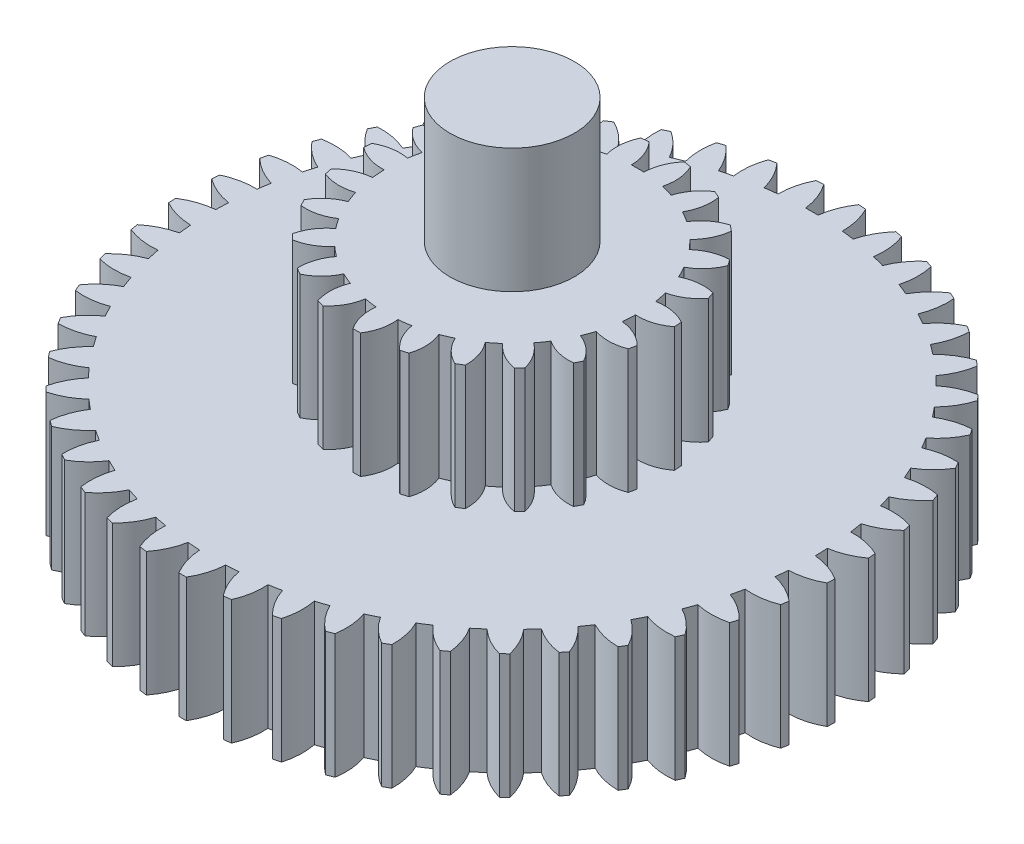
from build123d import *

# Parameters (mm, degrees)
BOSS_EXTRUDE1_DEPTH      = 1
SKETCH2_R                = 0.5
BOSS_EXTRUDE2_DEPTH      = 2
BOSS_EXTRUDE2_DEPTH_BACK = 2
BOSS_EXTRUDE3_DEPTH      = 1


with BuildPart() as part:
    # Sketch1 → Boss-Extrude1 (new body)
    with BuildSketch(Plane(origin=(0, 0, 0), x_dir=(1, 0, 0), z_dir=(0, 1, 0))):
        with BuildLine():
            ThreePointArc((-2.476479155, 0.943160111), (-2.486941318, 0.915217394), (-2.497088209, 0.887158654))
            ThreePointArc((-2.497088209, 0.887158654), (-2.405681699, 0.798131231), (-2.295665859, 0.733497284))
            ThreePointArc((-2.295665859, 0.733497284), (-2.310389526, 0.685711484), (-2.324118617, 0.637630499))
            ThreePointArc((-2.324118617, 0.637630499), (-2.451581658, 0.643479038), (-2.576755933, 0.618731655))
            ThreePointArc((-2.576755933, 0.618731655), (-2.583558967, 0.589680475), (-2.59003448, 0.560554541))
            ThreePointArc((-2.59003448, 0.560554541), (-2.487993842, 0.483946837), (-2.370616024, 0.433912047))
            ThreePointArc((-2.370616024, 0.433912047), (-2.379108098, 0.384635747), (-2.386576014, 0.335193869))
            ThreePointArc((-2.386576014, 0.335193869), (-2.513740479, 0.324694779), (-2.63472245, 0.284143641))
            ThreePointArc((-2.63472245, 0.284143641), (-2.637754649, 0.254461019), (-2.640452456, 0.224746138))
            ThreePointArc((-2.640452456, 0.224746138), (-2.529453195, 0.161816049), (-2.406640741, 0.127201987))
            ThreePointArc((-2.406640741, 0.127201987), (-2.408761781, 0.077244302), (-2.409845898, 0.027253365))
            ThreePointArc((-2.409845898, 0.027253365), (-2.534623752, 0.000579042), (-2.649426898, -0.055110003))
            ThreePointArc((-2.649426898, -0.055110003), (-2.648638473, -0.084936681), (-2.647514276, -0.114752591))
            ThreePointArc((-2.647514276, -0.114752591), (-2.529378996, -0.162971754), (-2.403148482, -0.181596727))
            ThreePointArc((-2.403148482, -0.181596727), (-2.398863662, -0.231415492), (-2.39354618, -0.281134638))
            ThreePointArc((-2.39354618, -0.281134638), (-2.513888572, -0.323546203), (-2.620627829, -0.393458742))
            ThreePointArc((-2.620627829, -0.393458742), (-2.616031726, -0.422939722), (-2.611103985, -0.452367085))
            ThreePointArc((-2.611103985, -0.452367085), (-2.487772464, -0.485083565), (-2.360196593, -0.487413627))
            ThreePointArc((-2.360196593, -0.487413627), (-2.349576268, -0.536275451), (-2.337944499, -0.584906419))
            ThreePointArc((-2.337944499, -0.584906419), (-2.451875411, -0.642358829), (-2.548798124, -0.7253469))
            ThreePointArc((-2.548798124, -0.7253469), (-2.540469811, -0.753998105), (-2.531819439, -0.782553724))
            ThreePointArc((-2.531819439, -0.782553724), (-2.405316777, -0.799230317), (-2.27849034, -0.78522721))
            ThreePointArc((-2.27849034, -0.78522721), (-2.261708897, -0.832329781), (-2.243953835, -0.879074052))
            ThreePointArc((-2.243953835, -0.879074052), (-2.349602524, -0.95062394), (-2.435117223, -1.045324882))
            ThreePointArc((-2.435117223, -1.045324882), (-2.423193451, -1.072675859), (-2.410962487, -1.099890852))
            ThreePointArc((-2.410962487, -1.099890852), (-2.283365855, -1.100253729), (-2.159371339, -1.070147383))
            ThreePointArc((-2.159371339, -1.070147383), (-2.136704328, -1.114717279), (-2.11311751, -1.158807313))
            ThreePointArc((-2.11311751, -1.158807313), (-2.208749229, -1.243279832), (-2.281451766, -1.348138658))
            ThreePointArc((-2.281451766, -1.348138658), (-2.266128322, -1.373740306), (-2.250517598, -1.399167803))
            ThreePointArc((-2.250517598, -1.399167803), (-2.123922129, -1.383211006), (-2.00479552, -1.337495765))
            ThreePointArc((-2.00479552, -1.337495765), (-1.976615134, -1.378801151), (-1.947583854, -1.419512991))
            ThreePointArc((-1.947583854, -1.419512991), (-2.031628332, -1.515521104), (-2.090324933, -1.628816034))
            ThreePointArc((-2.090324933, -1.628816034), (-2.071853429, -1.652247975), (-2.053119272, -1.675470458))
            ThreePointArc((-2.053119272, -1.675470458), (-1.92960366, -1.643455996), (-1.817301015, -1.582882504))
            ThreePointArc((-1.817301015, -1.582882504), (-1.784069973, -1.620245146), (-1.750070925, -1.656910304))
            ThreePointArc((-1.750070925, -1.656910304), (-1.821148154, -1.762877562), (-1.864875023, -1.882748297))
            ThreePointArc((-1.864875023, -1.882748297), (-1.843558759, -1.903625778), (-1.822008785, -1.924261933))
            ThreePointArc((-1.822008785, -1.924261933), (-1.703601153, -1.876715485), (-1.599966476, -1.802278357))
            ThreePointArc((-1.599966476, -1.802278357), (-1.562230433, -1.83508476), (-1.523821881, -1.867101196))
            ThreePointArc((-1.523821881, -1.867101196), (-1.580764774, -1.981287618), (-1.608803916, -2.105765884))
            ThreePointArc((-1.608803916, -2.105765884), (-1.584992906, -2.123746098), (-1.560980963, -2.141457081))
            ThreePointArc((-1.560980963, -2.141457081), (-1.449625561, -2.079159357), (-1.356360533, -1.992080848))
            ThreePointArc((-1.356360533, -1.992080848), (-1.314739112, -2.019792333), (-1.272551722, -2.046634338))
            ThreePointArc((-1.272551722, -2.046634338), (-1.31442528, -2.167164987), (-1.326316294, -2.294206854))
            ThreePointArc((-1.326316294, -2.294206854), (-1.300401513, -2.308994566), (-1.274321878, -2.323489563))
            ThreePointArc((-1.274321878, -2.323489563), (-1.171847158, -2.247463489), (-1.090483187, -2.149173427))
            ThreePointArc((-1.090483187, -2.149173427), (-1.045659811, -2.171334972), (-1.0003863, -2.192561801))
            ThreePointArc((-1.0003863, -2.192561801), (-1.026502959, -2.317457566), (-1.022050595, -2.44497701))
            ThreePointArc((-1.022050595, -2.44497701), (-0.994457563, -2.456329407), (-0.966738462, -2.467370411))
            ThreePointArc((-0.966738462, -2.467370411), (-0.874827057, -2.378864334), (-0.806700137, -2.270976638))
            ThreePointArc((-0.806700137, -2.270976638), (-0.759410805, -2.28722435), (-0.711794563, -2.302487459))
            ThreePointArc((-0.711794563, -2.302487459), (-0.721725488, -2.429697557), (-0.701002853, -2.555600712))
            ThreePointArc((-0.701002853, -2.555600712), (-0.672184647, -2.563331387), (-0.643281228, -2.570737105))
            ThreePointArc((-0.643281228, -2.570737105), (-0.56344232, -2.471204291), (-0.509671094, -2.355490475))
            ThreePointArc((-0.509671094, -2.355490475), (-0.460692295, -2.365557568), (-0.411515178, -2.374606338))
            ThreePointArc((-0.411515178, -2.374606338), (-0.405097304, -2.50204198), (-0.368444664, -2.624261521))
            ThreePointArc((-0.368444664, -2.624261521), (-0.338874478, -2.628243537), (-0.309261333, -2.631892366))
            ThreePointArc((-0.309261333, -2.631892366), (-0.242805876, -2.522967143), (-0.204273265, -2.401327223))
            ThreePointArc((-0.204273265, -2.401327223), (-0.15440923, -2.405048397), (-0.104478725, -2.407734245))
            ThreePointArc((-0.104478725, -2.407734245), (-0.081817434, -2.533302944), (-0.029836623, -2.649832028))
            ThreePointArc((-0.029836623, -2.649832028), (0, -2.65), (0.029836623, -2.649832028))
            ThreePointArc((0.029836623, -2.649832028), (0.081817434, -2.533302944), (0.104478725, -2.407734245))
            ThreePointArc((0.104478725, -2.407734245), (0.15440923, -2.405048397), (0.204273265, -2.401327223))
            ThreePointArc((0.204273265, -2.401327223), (0.242805876, -2.522967143), (0.309261333, -2.631892366))
            ThreePointArc((0.309261333, -2.631892366), (0.338874478, -2.628243537), (0.368444664, -2.624261521))
            ThreePointArc((0.368444664, -2.624261521), (0.405097304, -2.50204198), (0.411515178, -2.374606338))
            ThreePointArc((0.411515178, -2.374606338), (0.460692295, -2.365557568), (0.509671094, -2.355490475))
            ThreePointArc((0.509671094, -2.355490475), (0.56344232, -2.471204291), (0.643281228, -2.570737105))
            ThreePointArc((0.643281228, -2.570737105), (0.672184647, -2.563331387), (0.701002853, -2.555600712))
            ThreePointArc((0.701002853, -2.555600712), (0.721725488, -2.429697557), (0.711794563, -2.302487459))
            ThreePointArc((0.711794563, -2.302487459), (0.759410805, -2.28722435), (0.806700137, -2.270976638))
            ThreePointArc((0.806700137, -2.270976638), (0.874827057, -2.378864334), (0.966738462, -2.467370411))
            ThreePointArc((0.966738462, -2.467370411), (0.994457563, -2.456329407), (1.022050595, -2.44497701))
            ThreePointArc((1.022050595, -2.44497701), (1.026502959, -2.317457566), (1.0003863, -2.192561801))
            ThreePointArc((1.0003863, -2.192561801), (1.045659811, -2.171334972), (1.090483187, -2.149173427))
            ThreePointArc((1.090483187, -2.149173427), (1.171847158, -2.247463489), (1.274321878, -2.323489563))
            ThreePointArc((1.274321878, -2.323489563), (1.300401513, -2.308994566), (1.326316294, -2.294206854))
            ThreePointArc((1.326316294, -2.294206854), (1.31442528, -2.167164987), (1.272551722, -2.046634338))
            ThreePointArc((1.272551722, -2.046634338), (1.314739112, -2.019792333), (1.356360533, -1.992080848))
            ThreePointArc((1.356360533, -1.992080848), (1.449625561, -2.079159357), (1.560980963, -2.141457081))
            ThreePointArc((1.560980963, -2.141457081), (1.584992906, -2.123746098), (1.608803916, -2.105765884))
            ThreePointArc((1.608803916, -2.105765884), (1.580764774, -1.981287618), (1.523821881, -1.867101196))
            ThreePointArc((1.523821881, -1.867101196), (1.562230433, -1.83508476), (1.599966476, -1.802278357))
            ThreePointArc((1.599966476, -1.802278357), (1.703601153, -1.876715485), (1.822008785, -1.924261933))
            ThreePointArc((1.822008785, -1.924261933), (1.843558759, -1.903625778), (1.864875023, -1.882748297))
            ThreePointArc((1.864875023, -1.882748297), (1.821148154, -1.762877562), (1.750070925, -1.656910304))
            ThreePointArc((1.750070925, -1.656910304), (1.784069973, -1.620245146), (1.817301015, -1.582882504))
            ThreePointArc((1.817301015, -1.582882504), (1.92960366, -1.643455996), (2.053119272, -1.675470458))
            ThreePointArc((2.053119272, -1.675470458), (2.071853429, -1.652247975), (2.090324933, -1.628816034))
            ThreePointArc((2.090324933, -1.628816034), (2.031628332, -1.515521104), (1.947583854, -1.419512991))
            ThreePointArc((1.947583854, -1.419512991), (1.976615134, -1.378801151), (2.00479552, -1.337495765))
            ThreePointArc((2.00479552, -1.337495765), (2.123922129, -1.383211006), (2.250517598, -1.399167803))
            ThreePointArc((2.250517598, -1.399167803), (2.266128322, -1.373740306), (2.281451766, -1.348138658))
            ThreePointArc((2.281451766, -1.348138658), (2.208749229, -1.243279832), (2.11311751, -1.158807313))
            ThreePointArc((2.11311751, -1.158807313), (2.136704328, -1.114717279), (2.159371339, -1.070147383))
            ThreePointArc((2.159371339, -1.070147383), (2.283365855, -1.100253729), (2.410962487, -1.099890852))
            ThreePointArc((2.410962487, -1.099890852), (2.423193451, -1.072675859), (2.435117223, -1.045324882))
            ThreePointArc((2.435117223, -1.045324882), (2.349602524, -0.95062394), (2.243953835, -0.879074052))
            ThreePointArc((2.243953835, -0.879074052), (2.261708897, -0.832329781), (2.27849034, -0.78522721))
            ThreePointArc((2.27849034, -0.78522721), (2.405316777, -0.799230317), (2.531819439, -0.782553724))
            ThreePointArc((2.531819439, -0.782553724), (2.540469811, -0.753998105), (2.548798124, -0.7253469))
            ThreePointArc((2.548798124, -0.7253469), (2.451875411, -0.642358829), (2.337944499, -0.584906419))
            ThreePointArc((2.337944499, -0.584906419), (2.349576268, -0.536275451), (2.360196593, -0.487413627))
            ThreePointArc((2.360196593, -0.487413627), (2.487772464, -0.485083565), (2.611103985, -0.452367085))
            ThreePointArc((2.611103985, -0.452367085), (2.616031726, -0.422939722), (2.620627829, -0.393458742))
            ThreePointArc((2.620627829, -0.393458742), (2.513888572, -0.323546203), (2.39354618, -0.281134638))
            ThreePointArc((2.39354618, -0.281134638), (2.398863662, -0.231415492), (2.403148482, -0.181596727))
            ThreePointArc((2.403148482, -0.181596727), (2.529378996, -0.162971754), (2.647514276, -0.114752591))
            ThreePointArc((2.647514276, -0.114752591), (2.648638473, -0.084936681), (2.649426898, -0.055110003))
            ThreePointArc((2.649426898, -0.055110003), (2.534623752, 0.000579042), (2.409845898, 0.027253365))
            ThreePointArc((2.409845898, 0.027253365), (2.408761781, 0.077244302), (2.406640741, 0.127201987))
            ThreePointArc((2.406640741, 0.127201987), (2.529453195, 0.161816049), (2.640452456, 0.224746138))
            ThreePointArc((2.640452456, 0.224746138), (2.637754649, 0.254461019), (2.63472245, 0.284143641))
            ThreePointArc((2.63472245, 0.284143641), (2.513740479, 0.324694779), (2.386576014, 0.335193869))
            ThreePointArc((2.386576014, 0.335193869), (2.379108098, 0.384635747), (2.370616024, 0.433912047))
            ThreePointArc((2.370616024, 0.433912047), (2.487993842, 0.483946837), (2.59003448, 0.560554541))
            ThreePointArc((2.59003448, 0.560554541), (2.583558967, 0.589680475), (2.576755933, 0.618731655))
            ThreePointArc((2.576755933, 0.618731655), (2.451581658, 0.643479038), (2.324118617, 0.637630499))
            ThreePointArc((2.324118617, 0.637630499), (2.310389526, 0.685711484), (2.295665859, 0.733497284))
            ThreePointArc((2.295665859, 0.733497284), (2.405681699, 0.798131231), (2.497088209, 0.887158654))
            ThreePointArc((2.497088209, 0.887158654), (2.486941318, 0.915217394), (2.476479155, 0.943160111))
            ThreePointArc((2.476479155, 0.943160111), (2.349167934, 0.951697388), (2.223499257, 0.929597253))
            ThreePointArc((2.223499257, 0.929597253), (2.203734421, 0.975527857), (2.183020923, 1.021038516))
            ThreePointArc((2.183020923, 1.021038516), (2.283868329, 1.099210332), (2.363139819, 1.199195646))
            ThreePointArc((2.363139819, 1.199195646), (2.349488162, 1.225726469), (2.335538657, 1.252101905))
            ThreePointArc((2.335538657, 1.252101905), (2.208180937, 1.244288893), (2.086370101, 1.206300047))
            ThreePointArc((2.086370101, 1.206300047), (2.060894059, 1.24932609), (2.034530844, 1.291814323))
            ThreePointArc((2.034530844, 1.291814323), (2.124553904, 1.38224043), (2.190388738, 1.491541879))
            ThreePointArc((2.190388738, 1.491541879), (2.173456475, 1.516109149), (2.156248679, 1.54048422))
            ThreePointArc((2.156248679, 1.54048422), (2.03093567, 1.516449209), (1.914982805, 1.463195427))
            ThreePointArc((1.914982805, 1.463195427), (1.884213873, 1.502610422), (1.852633825, 1.541378575))
            ThreePointArc((1.852633825, 1.541378575), (1.930354363, 1.642574178), (1.981671535, 1.759397036))
            ThreePointArc((1.981671535, 1.759397036), (1.961736692, 1.781597359), (1.941553158, 1.803571827))
            ThreePointArc((1.941553158, 1.803571827), (1.820342495, 1.763709471), (1.712151544, 1.696065178))
            ThreePointArc((1.712151544, 1.696065178), (1.676594947, 1.731221934), (1.640316609, 1.765633433))
            ThreePointArc((1.640316609, 1.765633433), (1.704458457, 1.875936904), (1.74041534, 1.998362941))
            ThreePointArc((1.74041534, 1.998362941), (1.717805248, 2.01783179), (1.694977387, 2.037044835))
            ThreePointArc((1.694977387, 2.037044835), (1.579859347, 1.982009672), (1.481206803, 1.901085586))
            ThreePointArc((1.481206803, 1.901085586), (1.441446378, 1.931406829), (1.401065441, 1.96089664))
            ThreePointArc((1.401065441, 1.96089664), (1.45057539, 2.078496797), (1.470581573, 2.204515783))
            ThreePointArc((1.470581573, 2.204515783), (1.445667488, 2.220933478), (1.420570134, 2.237069622))
            ThreePointArc((1.420570134, 2.237069622), (1.313434953, 2.167765329), (1.225940687, 2.074890222))
            ThreePointArc((1.225940687, 2.074890222), (1.1826293, 2.099878077), (1.138808816, 2.123961977))
            ThreePointArc((1.138808816, 2.123961977), (1.172873915, 2.246927831), (1.176600897, 2.374470537))
            ThreePointArc((1.176600897, 2.374470537), (1.149791909, 2.3875675), (1.122837159, 2.400361788))
            ThreePointArc((1.122837159, 2.400361788), (1.025443992, 2.31792634), (0.950544658, 2.214625217))
            ThreePointArc((0.950544658, 2.214625217), (0.904393482, 2.233869385), (0.857852982, 2.252151918))
            ThreePointArc((0.857852982, 2.252151918), (0.875913883, 2.378464372), (0.863300467, 2.505436549))
            ThreePointArc((0.863300467, 2.505436549), (0.835036778, 2.51499773), (0.806667229, 2.52424008))
            ThreePointArc((0.806667229, 2.52424008), (0.72061527, 2.430027064), (0.659540713, 2.317996128))
            ThreePointArc((0.659540713, 2.317996128), (0.611307547, 2.33118062), (0.562811226, 2.343361586))
            ThreePointArc((0.562811226, 2.343361586), (0.564571369, 2.470946593), (0.535824668, 2.595263363))
            ThreePointArc((0.535824668, 2.595263363), (0.506570366, 2.601131766), (0.477251846, 2.606670419))
            ThreePointArc((0.477251846, 2.606670419), (0.403954065, 2.50222681), (0.357707127, 2.383305606))
            ThreePointArc((0.357707127, 2.383305606), (0.30818396, 2.390213933), (0.258528126, 2.396093322))
            ThreePointArc((0.258528126, 2.396093322), (0.243958609, 2.52285594), (0.199550642, 2.642476025))
            ThreePointArc((0.199550642, 2.642476025), (0.169786083, 2.644555291), (0.14, 2.646299303))
            ThreePointArc((0.14, 2.646299303), (0.080659945, 2.533340062), (0.05, 2.409481272))
            ThreePointArc((0.05, 2.409481272), (0, 2.41), (-0.05, 2.409481272))
            ThreePointArc((-0.05, 2.409481272), (-0.080659945, 2.533340062), (-0.14, 2.646299303))
            ThreePointArc((-0.14, 2.646299303), (-0.169786083, 2.644555291), (-0.199550642, 2.642476025))
            ThreePointArc((-0.199550642, 2.642476025), (-0.243958609, 2.52285594), (-0.258528126, 2.396093322))
            ThreePointArc((-0.258528126, 2.396093322), (-0.30818396, 2.390213933), (-0.357707127, 2.383305606))
            ThreePointArc((-0.357707127, 2.383305606), (-0.403954065, 2.50222681), (-0.477251846, 2.606670419))
            ThreePointArc((-0.477251846, 2.606670419), (-0.506570366, 2.601131766), (-0.535824668, 2.595263363))
            ThreePointArc((-0.535824668, 2.595263363), (-0.564571369, 2.470946593), (-0.562811226, 2.343361586))
            ThreePointArc((-0.562811226, 2.343361586), (-0.611307547, 2.33118062), (-0.659540713, 2.317996128))
            ThreePointArc((-0.659540713, 2.317996128), (-0.72061527, 2.430027064), (-0.806667229, 2.52424008))
            ThreePointArc((-0.806667229, 2.52424008), (-0.835036778, 2.51499773), (-0.863300467, 2.505436549))
            ThreePointArc((-0.863300467, 2.505436549), (-0.875913883, 2.378464372), (-0.857852982, 2.252151918))
            ThreePointArc((-0.857852982, 2.252151918), (-0.904393482, 2.233869385), (-0.950544658, 2.214625217))
            ThreePointArc((-0.950544658, 2.214625217), (-1.025443992, 2.31792634), (-1.122837159, 2.400361788))
            ThreePointArc((-1.122837159, 2.400361788), (-1.149791909, 2.3875675), (-1.176600897, 2.374470537))
            ThreePointArc((-1.176600897, 2.374470537), (-1.172873915, 2.246927831), (-1.138808816, 2.123961977))
            ThreePointArc((-1.138808816, 2.123961977), (-1.1826293, 2.099878077), (-1.225940687, 2.074890222))
            ThreePointArc((-1.225940687, 2.074890222), (-1.313434953, 2.167765329), (-1.420570134, 2.237069622))
            ThreePointArc((-1.420570134, 2.237069622), (-1.445667488, 2.220933478), (-1.470581573, 2.204515783))
            ThreePointArc((-1.470581573, 2.204515783), (-1.45057539, 2.078496797), (-1.401065441, 1.96089664))
            ThreePointArc((-1.401065441, 1.96089664), (-1.441446378, 1.931406829), (-1.481206803, 1.901085586))
            ThreePointArc((-1.481206803, 1.901085586), (-1.579859347, 1.982009672), (-1.694977387, 2.037044835))
            ThreePointArc((-1.694977387, 2.037044835), (-1.717805248, 2.01783179), (-1.74041534, 1.998362941))
            ThreePointArc((-1.74041534, 1.998362941), (-1.704458457, 1.875936904), (-1.640316609, 1.765633433))
            ThreePointArc((-1.640316609, 1.765633433), (-1.676594947, 1.731221934), (-1.712151544, 1.696065178))
            ThreePointArc((-1.712151544, 1.696065178), (-1.820342495, 1.763709471), (-1.941553158, 1.803571827))
            ThreePointArc((-1.941553158, 1.803571827), (-1.961736692, 1.781597359), (-1.981671535, 1.759397036))
            ThreePointArc((-1.981671535, 1.759397036), (-1.930354363, 1.642574178), (-1.852633825, 1.541378575))
            ThreePointArc((-1.852633825, 1.541378575), (-1.884213873, 1.502610422), (-1.914982805, 1.463195427))
            ThreePointArc((-1.914982805, 1.463195427), (-2.03093567, 1.516449209), (-2.156248679, 1.54048422))
            ThreePointArc((-2.156248679, 1.54048422), (-2.173456475, 1.516109149), (-2.190388738, 1.491541879))
            ThreePointArc((-2.190388738, 1.491541879), (-2.124553904, 1.38224043), (-2.034530844, 1.291814323))
            ThreePointArc((-2.034530844, 1.291814323), (-2.060894059, 1.24932609), (-2.086370101, 1.206300047))
            ThreePointArc((-2.086370101, 1.206300047), (-2.208180937, 1.244288893), (-2.335538657, 1.252101905))
            ThreePointArc((-2.335538657, 1.252101905), (-2.349488162, 1.225726469), (-2.363139819, 1.199195646))
            ThreePointArc((-2.363139819, 1.199195646), (-2.283868329, 1.099210332), (-2.183020923, 1.021038516))
            ThreePointArc((-2.183020923, 1.021038516), (-2.203734421, 0.975527857), (-2.223499257, 0.929597253))
            ThreePointArc((-2.223499257, 0.929597253), (-2.349167934, 0.951697388), (-2.476479155, 0.943160111))
        make_face()
    extrude(amount=BOSS_EXTRUDE1_DEPTH)

    # Sketch2 → Boss-Extrude2 (add, two sides)
    with BuildSketch(Plane(origin=(0, 1, 0), x_dir=(1, 0, 0), z_dir=(0, 1, 0))) as boss_extrude2_sk:
        Circle(SKETCH2_R)
    extrude(amount=BOSS_EXTRUDE2_DEPTH)
    extrude(boss_extrude2_sk.sketch, amount=-BOSS_EXTRUDE2_DEPTH_BACK)

    # Sketch3 → Boss-Extrude3 (add)
    with BuildSketch(Plane(origin=(0, 1, 0), x_dir=(1, 0, 0), z_dir=(0, 1, 0))):
        with BuildLine():
            ThreePointArc((-1.16728264, 0.447159074), (-1.177826153, 0.418599515), (-1.187671024, 0.38979166))
            ThreePointArc((-1.187671024, 0.38979166), (-1.094599992, 0.303361491), (-0.977489647, 0.254192821))
            ThreePointArc((-0.977489647, 0.254192821), (-0.988874929, 0.205490573), (-0.997835248, 0.156284412))
            ThreePointArc((-0.997835248, 0.156284412), (-1.124839032, 0.157843241), (-1.244638708, 0.115648115))
            ThreePointArc((-1.244638708, 0.115648115), (-1.247085961, 0.085303017), (-1.248793492, 0.05490732))
            ThreePointArc((-1.248793492, 0.05490732), (-1.135855206, -0.003207519), (-1.009822082, -0.018956889))
            ThreePointArc((-1.009822082, -0.018956889), (-1.007645457, -0.068924837), (-1.00299784, -0.118723766))
            ThreePointArc((-1.00299784, -0.118723766), (-1.125712546, -0.151487953), (-1.229685616, -0.224439935))
            ThreePointArc((-1.229685616, -0.224439935), (-1.22385511, -0.254320016), (-1.21729866, -0.284049244))
            ThreePointArc((-1.21729866, -0.284049244), (-1.092869235, -0.309538643), (-0.967260632, -0.290700653))
            ThreePointArc((-0.967260632, -0.290700653), (-0.951683531, -0.338228408), (-0.933772671, -0.384926745))
            ThreePointArc((-0.933772671, -0.384926745), (-1.043097111, -0.449583979), (-1.123532368, -0.547882303))
            ThreePointArc((-1.123532368, -0.547882303), (-1.109856523, -0.575081297), (-1.095522354, -0.601939176))
            ThreePointArc((-1.095522354, -0.601939176), (-0.968830153, -0.592912701), (-0.852961886, -0.54088448))
            ThreePointArc((-0.852961886, -0.54088448), (-0.825139592, -0.582447125), (-0.795293854, -0.622581469))
            ThreePointArc((-0.795293854, -0.622581469), (-0.883119934, -0.714336418), (-0.934051864, -0.830690746))
            ThreePointArc((-0.934051864, -0.830690746), (-0.913544955, -0.853191429), (-0.892496167, -0.875186032))
            ThreePointArc((-0.892496167, -0.875186032), (-0.772937371, -0.832313137), (-0.67540286, -0.750953379))
            ThreePointArc((-0.67540286, -0.750953379), (-0.637398824, -0.783468404), (-0.597831731, -0.814062173))
            ThreePointArc((-0.597831731, -0.814062173), (-0.657645793, -0.926109793), (-0.675297006, -1.051890657))
            ThreePointArc((-0.675297006, -1.051890657), (-0.649479938, -1.068024256), (-0.623277623, -1.083524344))
            ThreePointArc((-0.623277623, -1.083524344), (-0.519719359, -1.009984715), (-0.447752293, -0.905327501))
            ThreePointArc((-0.447752293, -0.905327501), (-0.402385101, -0.926383415), (-0.356031163, -0.94516761))
            ThreePointArc((-0.356031163, -0.94516761), (-0.383397071, -1.069197841), (-0.366458458, -1.19507665))
            ThreePointArc((-0.366458458, -1.19507665), (-0.337245964, -1.203646609), (-0.307833428, -1.211502613))
            ThreePointArc((-0.307833428, -1.211502613), (-0.227956141, -1.112750347), (-0.186893986, -0.992557624))
            ThreePointArc((-0.186893986, -0.992557624), (-0.137528316, -1.000592805), (-0.087825392, -1.006174289))
            ThreePointArc((-0.087825392, -1.006174289), (-0.080713542, -1.132988376), (-0.030441363, -1.249629274))
            ThreePointArc((-0.030441363, -1.249629274), (0, -1.25), (0.030441363, -1.249629274))
            ThreePointArc((0.030441363, -1.249629274), (0.080713542, -1.132988376), (0.087825392, -1.006174289))
            ThreePointArc((0.087825392, -1.006174289), (0.137528316, -1.000592805), (0.186893986, -0.992557624))
            ThreePointArc((0.186893986, -0.992557624), (0.227956141, -1.112750347), (0.307833428, -1.211502613))
            ThreePointArc((0.307833428, -1.211502613), (0.337245964, -1.203646609), (0.366458458, -1.19507665))
            ThreePointArc((0.366458458, -1.19507665), (0.383397071, -1.069197841), (0.356031163, -0.94516761))
            ThreePointArc((0.356031163, -0.94516761), (0.402385101, -0.926383415), (0.447752293, -0.905327501))
            ThreePointArc((0.447752293, -0.905327501), (0.519719359, -1.009984715), (0.623277623, -1.083524344))
            ThreePointArc((0.623277623, -1.083524344), (0.649479938, -1.068024256), (0.675297006, -1.051890657))
            ThreePointArc((0.675297006, -1.051890657), (0.657645793, -0.926109793), (0.597831731, -0.814062173))
            ThreePointArc((0.597831731, -0.814062173), (0.637398824, -0.783468404), (0.67540286, -0.750953379))
            ThreePointArc((0.67540286, -0.750953379), (0.772937371, -0.832313137), (0.892496167, -0.875186032))
            ThreePointArc((0.892496167, -0.875186032), (0.913544955, -0.853191429), (0.934051864, -0.830690746))
            ThreePointArc((0.934051864, -0.830690746), (0.883119934, -0.714336418), (0.795293854, -0.622581469))
            ThreePointArc((0.795293854, -0.622581469), (0.825139592, -0.582447125), (0.852961886, -0.54088448))
            ThreePointArc((0.852961886, -0.54088448), (0.968830153, -0.592912701), (1.095522354, -0.601939176))
            ThreePointArc((1.095522354, -0.601939176), (1.109856523, -0.575081297), (1.123532368, -0.547882303))
            ThreePointArc((1.123532368, -0.547882303), (1.043097111, -0.449583979), (0.933772671, -0.384926745))
            ThreePointArc((0.933772671, -0.384926745), (0.951683531, -0.338228408), (0.967260632, -0.290700653))
            ThreePointArc((0.967260632, -0.290700653), (1.092869235, -0.309538643), (1.21729866, -0.284049244))
            ThreePointArc((1.21729866, -0.284049244), (1.22385511, -0.254320016), (1.229685616, -0.224439935))
            ThreePointArc((1.229685616, -0.224439935), (1.125712546, -0.151487953), (1.00299784, -0.118723766))
            ThreePointArc((1.00299784, -0.118723766), (1.007645457, -0.068924837), (1.009822082, -0.018956889))
            ThreePointArc((1.009822082, -0.018956889), (1.135855206, -0.003207519), (1.248793492, 0.05490732))
            ThreePointArc((1.248793492, 0.05490732), (1.247085961, 0.085303017), (1.244638708, 0.115648115))
            ThreePointArc((1.244638708, 0.115648115), (1.124839032, 0.157843241), (0.997835248, 0.156284412))
            ThreePointArc((0.997835248, 0.156284412), (0.988874929, 0.205490573), (0.977489647, 0.254192821))
            ThreePointArc((0.977489647, 0.254192821), (1.094599992, 0.303361491), (1.187671024, 0.38979166))
            ThreePointArc((1.187671024, 0.38979166), (1.177826153, 0.418599515), (1.16728264, 0.447159074))
            ThreePointArc((1.16728264, 0.447159074), (1.040541353, 0.455467925), (0.918667781, 0.41970169))
            ThreePointArc((0.918667781, 0.41970169), (0.896764071, 0.464665688), (0.872661277, 0.508490212))
            ThreePointArc((0.872661277, 0.508490212), (0.972163304, 0.587431568), (1.03846443, 0.695766935))
            ThreePointArc((1.03846443, 0.695766935), (1.021212366, 0.720850403), (1.003354559, 0.74550629))
            ThreePointArc((1.003354559, 0.74550629), (0.879071481, 0.719312636), (0.771366926, 0.651991614))
            ThreePointArc((0.771366926, 0.651991614), (0.738144324, 0.689378675), (0.703111612, 0.725075211))
            ThreePointArc((0.703111612, 0.725075211), (0.777625711, 0.827934532), (0.812239679, 0.95014036))
            ThreePointArc((0.812239679, 0.95014036), (0.78885993, 0.969639113), (0.765012261, 0.988562715))
            ThreePointArc((0.765012261, 0.988562715), (0.652404899, 0.929809219), (0.566857316, 0.835926303))
            ThreePointArc((0.566857316, 0.835926303), (0.52477979, 0.862963599), (0.481415375, 0.887884698))
            ThreePointArc((0.481415375, 0.887884698), (0.525415177, 1.00703338), (0.525774827, 1.134046221))
            ThreePointArc((0.525774827, 1.134046221), (0.498001362, 1.146514127), (0.469932502, 1.158301966))
            ThreePointArc((0.469932502, 1.158301966), (0.377352431, 1.071346106), (0.320306492, 0.957864161))
            ThreePointArc((0.320306492, 0.957864161), (0.272494739, 0.97254646), (0.224014763, 0.984843838))
            ThreePointArc((0.224014763, 0.984843838), (0.234237003, 1.111445169), (0.200315662, 1.233845061))
            ThreePointArc((0.200315662, 1.233845061), (0.170208311, 1.238357433), (0.14, 1.242135258))
            ThreePointArc((0.14, 1.242135258), (0.074313459, 1.133426154), (0.05, 1.008761617))
            ThreePointArc((0.05, 1.008761617), (0, 1.01), (-0.05, 1.008761617))
            ThreePointArc((-0.05, 1.008761617), (-0.074313459, 1.133426154), (-0.14, 1.242135258))
            ThreePointArc((-0.14, 1.242135258), (-0.170208311, 1.238357433), (-0.200315662, 1.233845061))
            ThreePointArc((-0.200315662, 1.233845061), (-0.234237003, 1.111445169), (-0.224014763, 0.984843838))
            ThreePointArc((-0.224014763, 0.984843838), (-0.272494739, 0.97254646), (-0.320306492, 0.957864161))
            ThreePointArc((-0.320306492, 0.957864161), (-0.377352431, 1.071346106), (-0.469932502, 1.158301966))
            ThreePointArc((-0.469932502, 1.158301966), (-0.498001362, 1.146514127), (-0.525774827, 1.134046221))
            ThreePointArc((-0.525774827, 1.134046221), (-0.525415177, 1.00703338), (-0.481415375, 0.887884698))
            ThreePointArc((-0.481415375, 0.887884698), (-0.52477979, 0.862963599), (-0.566857316, 0.835926303))
            ThreePointArc((-0.566857316, 0.835926303), (-0.652404899, 0.929809219), (-0.765012261, 0.988562715))
            ThreePointArc((-0.765012261, 0.988562715), (-0.78885993, 0.969639113), (-0.812239679, 0.95014036))
            ThreePointArc((-0.812239679, 0.95014036), (-0.777625711, 0.827934532), (-0.703111612, 0.725075211))
            ThreePointArc((-0.703111612, 0.725075211), (-0.738144324, 0.689378675), (-0.771366926, 0.651991614))
            ThreePointArc((-0.771366926, 0.651991614), (-0.879071481, 0.719312636), (-1.003354559, 0.74550629))
            ThreePointArc((-1.003354559, 0.74550629), (-1.021212366, 0.720850403), (-1.03846443, 0.695766935))
            ThreePointArc((-1.03846443, 0.695766935), (-0.972163304, 0.587431568), (-0.872661277, 0.508490212))
            ThreePointArc((-0.872661277, 0.508490212), (-0.896764071, 0.464665688), (-0.918667781, 0.41970169))
            ThreePointArc((-0.918667781, 0.41970169), (-1.040541353, 0.455467925), (-1.16728264, 0.447159074))
        make_face()
    extrude(amount=BOSS_EXTRUDE3_DEPTH)


solid = part.part
